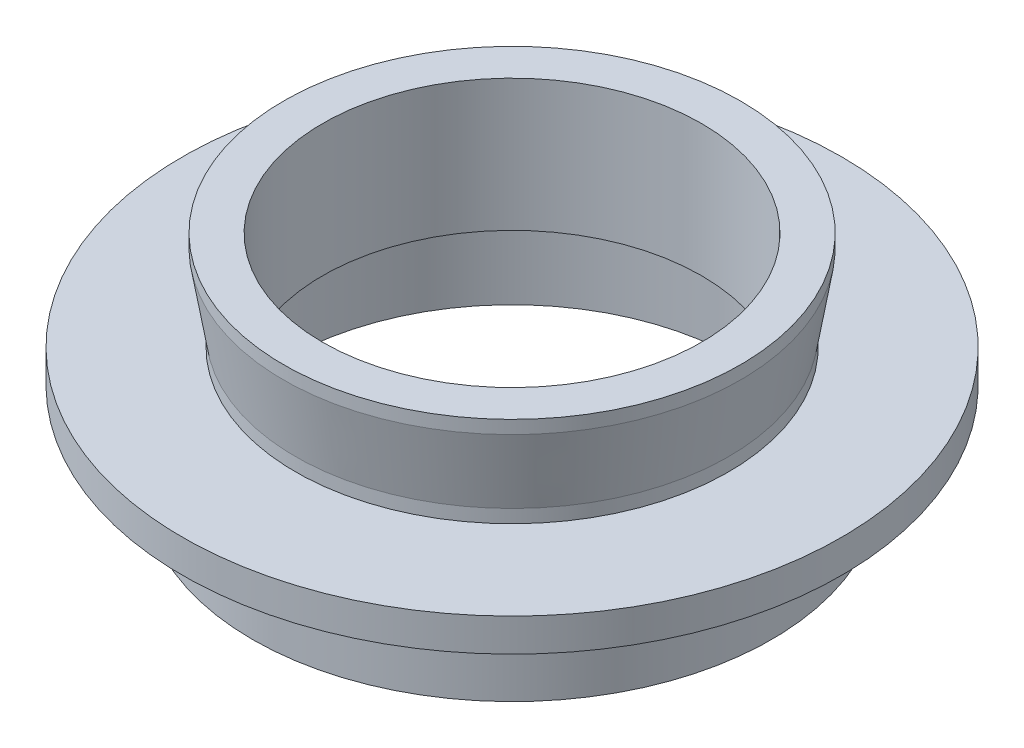
from build123d import *


with BuildPart() as part:
    # 草图1 → 旋转1 (revolve)
    with BuildSketch(Plane.XY, mode=Mode.PRIVATE) as revolve_1_sk:
        Polygon((-11.5, 5), (-11.5, 13), (-13.865, 13), (-13.865, 12.2), (-13.135, 7.8), (-13.135, 7), (-20, 7), (-20, 5), (-15.75, 5), (-15.75, -0.5), (-13.75, -0.5), (-13.75, 4), (-14.5, 4), (-14.5, 5), align=None)
    revolve(revolve_1_sk.sketch.rotate(Axis((0, 0, 0), (0, 1, 0)), 270), axis=Axis((0, 0, 0), (0, 1, 0)))  # turned: the seam where the file's is


solid = part.part
